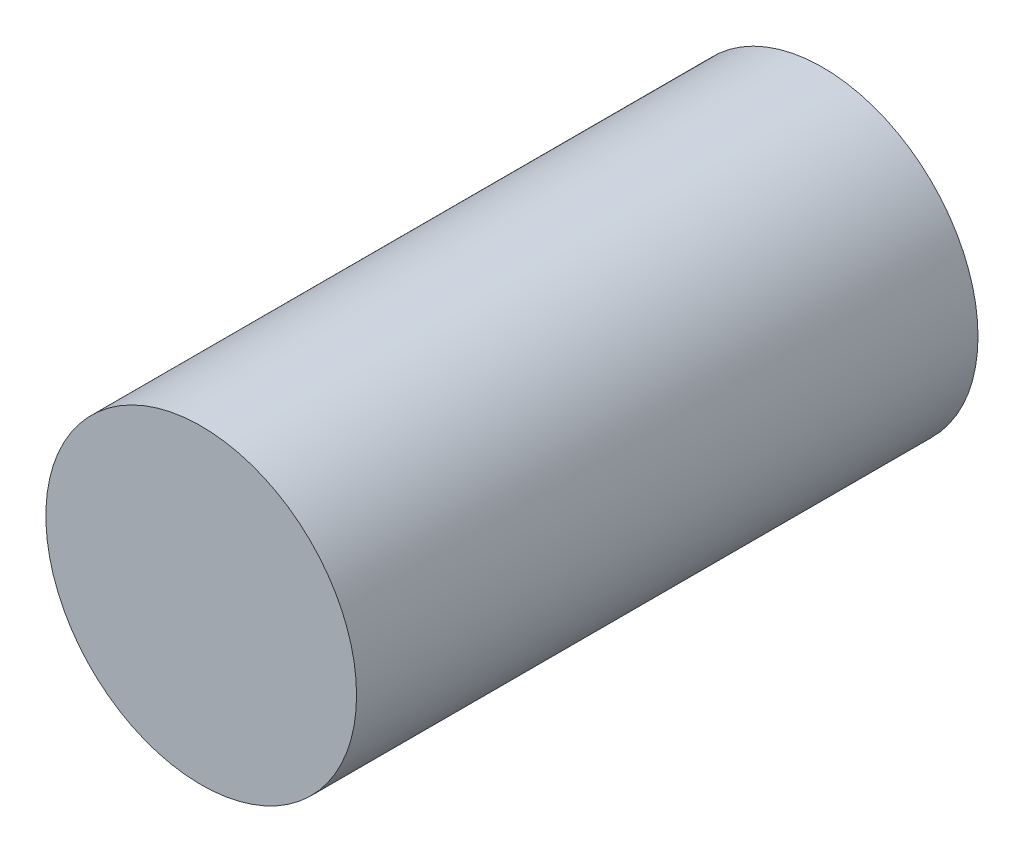
from build123d import *

# Parameters (mm, degrees)
CROQUIS1_R              = 0.25
SALIENTE_EXTRUIR1_DEPTH = 1


with BuildPart() as part:
    # Croquis1 → Saliente-Extruir1 (new body)
    with BuildSketch(Plane.XY):
        Circle(CROQUIS1_R)
    extrude(amount=SALIENTE_EXTRUIR1_DEPTH)


solid = part.part
